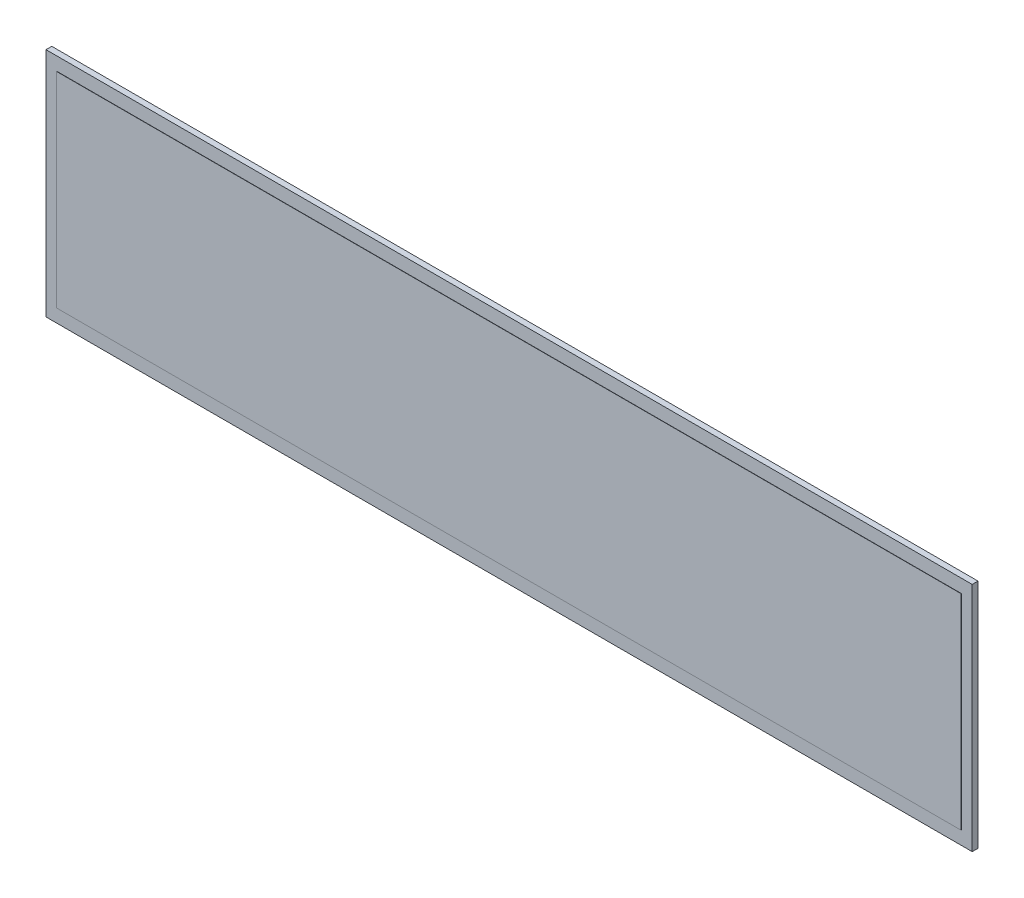
from build123d import *

# Parameters (mm, degrees)
SKETCH1_W           = 689.102
SKETCH1_H           = 172.212
BOSS_EXTRUDE1_DEPTH = 2.159
SKETCH2_W           = 673.1
SKETCH2_H           = 152.4
BOSS_EXTRUDE2_DEPTH = 0.2032


with BuildPart() as part:
    # Sketch1 → Boss-Extrude1 (new body, symmetric)
    with BuildSketch(Plane.XY):
        Rectangle(SKETCH1_W, SKETCH1_H)
    extrude(amount=BOSS_EXTRUDE1_DEPTH, both=True)

    # Sketch2 → Boss-Extrude2 (add)
    with BuildSketch(Plane.XY.offset(2.159)):
        Rectangle(SKETCH2_W, SKETCH2_H)
    extrude(amount=BOSS_EXTRUDE2_DEPTH)


solid = part.part
